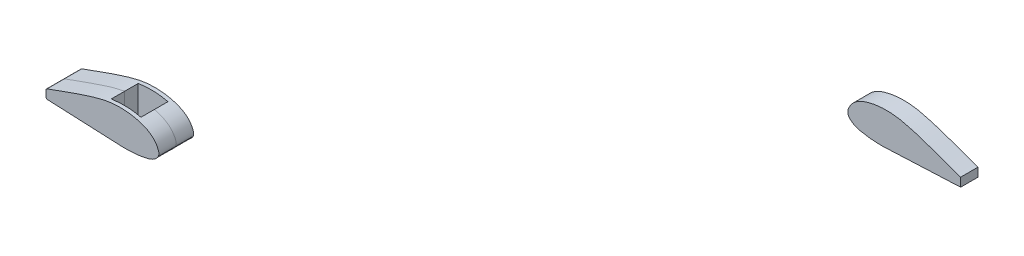
from build123d import *

# Parameters (mm, degrees)
BOSS_EXTRUDE2_DEPTH     = 50.8
FILLET2_R               = 5
SKETCH5_W               = 87
SKETCH5_H               = 39.5
CUT_EXTRUDE1_DEPTH      = 94.751189975
CUT_EXTRUDE1_DEPTH_BACK = 4.056749877
BOSS_EXTRUDE4_DEPTH     = 39.5
BOSS_EXTRUDE3_DEPTH     = 50.8


with BuildPart() as part:
    # Sketch2 → Boss-Extrude2 (new body)
    with BuildSketch(Plane.XY):
        with BuildLine():
            Line((-106.722779814, -3.056749777), (-333.799577852, 7.21966339))
            Line((-333.799577852, 7.21966339), (-333.799577852, 32.733633757))
            add(Edge.make_bspline(
                [(-333.799577852, 32.733633757), (-329.123726706, 34.274992563), (-319.792816147, 37.412373922), (-301.212500591, 43.993367263), (-278.05318635, 52.547373307), (-250.212100944, 62.815163989), (-222.109601473, 72.460113993), (-193.72137012, 81.15865237), (-169.694652242, 87.692123859), (-150.08564319, 91.413869046), (-135.175567465, 93.181488739), (-120.169525086, 93.901172546), (-105.14233718, 93.595533925), (-90.164680094, 92.267822954), (-75.313897799, 89.833517635), (-60.693438177, 86.228283506), (-46.341530434, 81.328395303), (-34.956343241, 75.643918425), (-26.449592019, 69.84976709), (-20.529561544, 64.86916439), (-15.215336755, 59.226873702), (-10.696946545, 52.930591349), (-7.612782659, 47.276191858), (-5.490715451, 42.580212712), (-4.135515755, 38.799833308), (-3.321928596, 34.715234365), (-3.33908171, 31.094028976), (-3.898094383, 28.213409742), (-4.898009423, 25.401657881), (-6.733503696, 22.398378039), (-9.223018864, 19.282206961), (-12.026298866, 16.432944726), (-15.068947941, 13.897940857), (-19.382255095, 10.912240948), (-25.117278078, 7.921604732), (-32.359594325, 5.276264911), (-39.801155453, 3.324217396), (-47.299282261, 1.834669556), (-54.681916309, 0.547958399), (-62.04945499, -0.600386665), (-69.48294113, -1.499644473), (-79.441609879, -2.332621433), (-91.864314175, -2.8892729), (-101.766415387, -3.01911256), (-106.722779814, -3.056749777)],
                knots=[-0.003832134, -0.003832134, -0.003832134, -0.003832134, 0.02754199, 0.058916113, 0.12166436, 0.184412607, 0.247160854, 0.3099091, 0.372657347, 0.40403147, 0.435405594, 0.466779717, 0.498153841, 0.529527964, 0.560902087, 0.592276211, 0.623650334, 0.655024458, 0.670711519, 0.686398581, 0.702085643, 0.717772704, 0.733459766, 0.741303297, 0.749146828, 0.756990359, 0.764833889, 0.768755655, 0.77267742, 0.780520951, 0.788364482, 0.796208013, 0.804051544, 0.811895075, 0.827582136, 0.843269198, 0.85895626, 0.874643321, 0.890330383, 0.906017445, 0.921704506, 0.937391568, 0.968765691, 1.000139815, 1.000139815, 1.000139815, 1.000139815], degree=3))
        make_face()
    extrude(amount=BOSS_EXTRUDE2_DEPTH)

    # Fillet2
    fillet2_edges = [part.edges().sort_by_distance(p)[0] for p in [
        (-333.799577852, 7.21966339, 25.4),
        (-333.799577852, 32.733633757, 25.4),
    ]]
    fillet(fillet2_edges, radius=FILLET2_R)

    # Sketch5 → Cut-Extrude1 (cut, two sides)
    with BuildSketch(Plane(origin=(0, 0, 0), x_dir=(1, 0, 0), z_dir=(0, 1, 0))) as cut_extrude1_sk:
        with Locations((-110.74742333, -31.05)):
            Rectangle(SKETCH5_W, SKETCH5_H)
    extrude(amount=CUT_EXTRUDE1_DEPTH, mode=Mode.SUBTRACT)
    extrude(cut_extrude1_sk.sketch, amount=-CUT_EXTRUDE1_DEPTH_BACK, mode=Mode.SUBTRACT)


with BuildPart() as body_2:
    # Sketch7 → Boss-Extrude4 (new body)
    with BuildSketch(Plane.XY.offset(11.3)):
        with BuildLine():
            Line((-154.24742333, -0.906011011), (-106.722779814, -3.056749777))
            add(Edge.make_bspline(
                [(-106.722779814, -3.056749777), (-101.766415387, -3.01911256), (-91.864314175, -2.8892729), (-79.441609879, -2.332621433), (-71.223098072, -1.645197125), (-67.993940291, -1.296811964), (-67.24742333, -1.212168414)],
                knots=[0.916981942, 0.916981942, 0.916981942, 0.916981942, 0.948356065, 0.979730189, 0.995417251, 1.000139815, 1.000139815, 1.000139815, 1.000139815], degree=3))
            Line((-67.24742333, -1.212168414), (-67.24742333, 4.787831586))
            Line((-67.24742333, 4.787831586), (-154.24742333, 4.787831586))
            Line((-154.24742333, 4.787831586), (-154.24742333, -0.906011011))
        make_face()
    extrude(amount=BOSS_EXTRUDE4_DEPTH)


with BuildPart() as body_3:
    # Mirror1: mirrored copy
    add(part.part.mirror(Plane.XY.offset(50.8)))


with BuildPart() as body_4:
    # Mirror1 2: mirrored copy
    add(body_2.part.mirror(Plane.XY.offset(50.8)))


with BuildPart() as body_5:
    # Sketch6 → Boss-Extrude3 (new body)
    with BuildSketch(Plane(origin=(0, 0, 0), x_dir=(-1, 0, 0), z_dir=(0, 0, -1))):
        with BuildLine():
            Line((-2014.516495435, 1009.481001687), (-2241.593293473, 1019.757414854))
            Line((-2241.593293473, 1019.757414854), (-2241.593293473, 1045.271385222))
            add(Edge.make_bspline(
                [(-2241.593293473, 1045.271385222), (-2236.917442327, 1046.812744027), (-2227.586531768, 1049.950125386), (-2209.006216213, 1056.531118727), (-2185.846901971, 1065.085124772), (-2158.005816566, 1075.352915454), (-2129.903317094, 1084.997865457), (-2101.515085741, 1093.696403834), (-2077.488367864, 1100.229875324), (-2057.879358811, 1103.951620511), (-2042.969283086, 1105.719240204), (-2027.963240707, 1106.438924011), (-2012.936052801, 1106.133285389), (-1997.958395715, 1104.805574418), (-1983.107613421, 1102.371269099), (-1968.487153799, 1098.76603497), (-1954.135246055, 1093.866146768), (-1942.750058862, 1088.18166989), (-1934.243307641, 1082.387518554), (-1928.323277165, 1077.406915854), (-1923.009052376, 1071.764625166), (-1918.490662166, 1065.468342813), (-1915.40649828, 1059.813943322), (-1913.284431072, 1055.117964177), (-1911.929231376, 1051.337584772), (-1911.115644217, 1047.252985829), (-1911.132797332, 1043.63178044), (-1911.691810004, 1040.751161207), (-1912.691725044, 1037.939409345), (-1914.527219317, 1034.936129503), (-1917.016734486, 1031.819958425), (-1919.820014487, 1028.970696191), (-1922.862663562, 1026.435692321), (-1927.175970716, 1023.449992412), (-1932.9109937, 1020.459356197), (-1940.153309946, 1017.814016376), (-1947.594871074, 1015.86196886), (-1955.092997882, 1014.372421021), (-1962.47563193, 1013.085709864), (-1969.843170611, 1011.9373648), (-1977.276656752, 1011.038106991), (-1987.235325501, 1010.205130032), (-1999.658029796, 1009.648478564), (-2009.560131008, 1009.518638905), (-2014.516495435, 1009.481001687)],
                knots=[-0.003832134, -0.003832134, -0.003832134, -0.003832134, 0.02754199, 0.058916113, 0.12166436, 0.184412607, 0.247160854, 0.3099091, 0.372657347, 0.40403147, 0.435405594, 0.466779717, 0.498153841, 0.529527964, 0.560902087, 0.592276211, 0.623650334, 0.655024458, 0.670711519, 0.686398581, 0.702085643, 0.717772704, 0.733459766, 0.741303297, 0.749146828, 0.756990359, 0.764833889, 0.768755655, 0.77267742, 0.780520951, 0.788364482, 0.796208013, 0.804051544, 0.811895075, 0.827582136, 0.843269198, 0.85895626, 0.874643321, 0.890330383, 0.906017445, 0.921704506, 0.937391568, 0.968765691, 1.000139815, 1.000139815, 1.000139815, 1.000139815], degree=3))
        make_face()
    extrude(amount=BOSS_EXTRUDE3_DEPTH)


solid = Compound([part.part, body_2.part, body_3.part, body_4.part, body_5.part])
